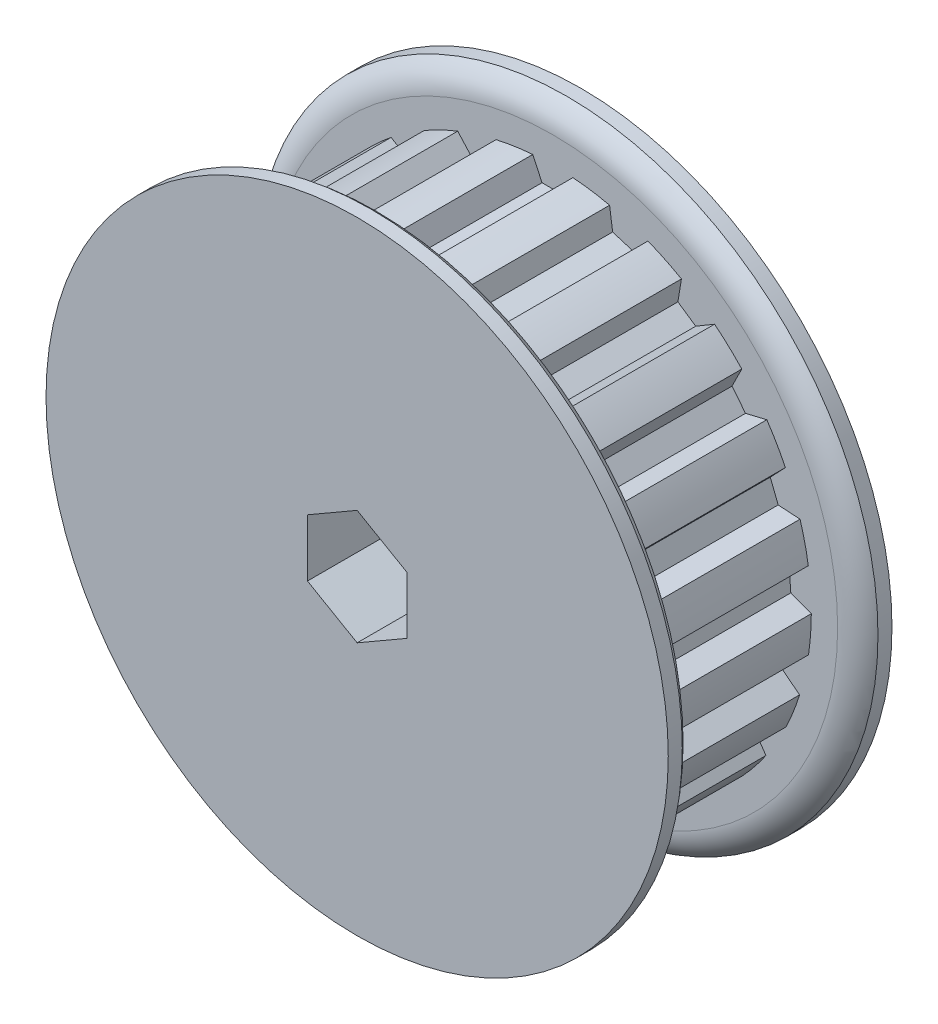
from build123d import *

# Parameters (mm, degrees)
CUT_EXTRUDE1_START = 1.397
CUT_EXTRUDE1_DEPTH = 10.7188
CIRPATTERN1_COUNT  = 21
SKETCH4_R          = 1.5875
CUT_EXTRUDE2_DEPTH = 31.241836167
CUT_EXTRUDE3_DEPTH = 1.190625
CIRPATTERN2_COUNT  = 2
CIRPATTERN2_ANGLE  = 90
CUT_EXTRUDE4_DEPTH = 50.8
SKETCH8_R          = 12.7
CUT_EXTRUDE5_DEPTH = 50.8


with BuildPart() as part:
    # Sketch2 → Revolve1 (revolve)
    with BuildSketch(Plane(origin=(0, 0, 0), x_dir=(0, 0, -1), z_dir=(1, 0, 0)), mode=Mode.PRIVATE) as revolve1_sk:
        with BuildLine():
            Line((-11.1125, 3.175), (11.1125, 3.175))
            Line((11.1125, 3.175), (11.1125, 19.8882))
            Line((11.1125, 19.8882), (10.21715, 19.8882))
            ThreePointArc((10.21715, 19.8882), (9.559562343, 19.158250378), (9.3218, 18.204983865))
            Line((9.3218, 18.204983865), (9.3218, 16.521767729))
            Line((9.3218, 16.521767729), (-1.397, 16.521767729))
            Line((-1.397, 16.521767729), (-1.397, 18.204983865))
            ThreePointArc((-1.397, 18.204983865), (-1.634762343, 19.158250378), (-2.29235, 19.8882))
            Line((-2.29235, 19.8882), (-3.1877, 19.8882))
            Line((-3.1877, 19.8882), (-3.1877, 11.9126))
            Line((-3.1877, 11.9126), (-11.1125, 11.9126))
            Line((-11.1125, 11.9126), (-11.1125, 3.175))
        make_face()
    revolve(revolve1_sk.sketch.rotate(Axis((0, 0, 11.1125), (0, 0, -1)), 90), axis=Axis((0, 0, 11.1125), (0, 0, -1)))

    # Sketch3 → Cut-Extrude1 (cut)
    with BuildSketch(Plane.XY.offset(CUT_EXTRUDE1_START)):
        with BuildLine():
            Line((-0.690489274, 15.2019), (0.690489274, 15.2019))
            Line((0.690489274, 15.2019), (1.2827, 16.4719))
            ThreePointArc((1.2827, 16.4719), (0, 16.521767729), (-1.2827, 16.4719))
            Line((-1.2827, 16.4719), (-0.690489274, 15.2019))
        make_face()
    cut_extrude1 = extrude(amount=-CUT_EXTRUDE1_DEPTH, mode=Mode.SUBTRACT)

    # CirPattern1: Cut-Extrude1 ×21 about axis
    cirpattern1_axis = Axis((0, 0, 0), (0, 0, 1))
    for i in range(1, CIRPATTERN1_COUNT):
        add(cut_extrude1.rotate(cirpattern1_axis, i * 360 / CIRPATTERN1_COUNT), mode=Mode.SUBTRACT)

    # Sketch4 → Cut-Extrude2 (cut, through all)
    with BuildSketch(Plane(origin=(0, 0, 0), x_dir=(1, 0, 0), z_dir=(0, 1, 0))):
        with Locations(Location((0, -7.1501, 0), (0, 0, 90))):
            Circle(SKETCH4_R)
    cut_extrude2 = extrude(amount=CUT_EXTRUDE2_DEPTH, mode=Mode.SUBTRACT)

    # Sketch5 → Revolve2 (revolve)
    with BuildSketch(Plane.XY.offset(7.1501), mode=Mode.PRIVATE) as revolve2_sk:
        Polygon((1.0795, 11.806349246), (1.5875, 11.298349246), (1.5875, 3.81), (0.9525, 3.175), (0, 3.175), (0, 11.806349246), align=None)
    revolve2 = revolve(revolve2_sk.sketch.rotate(Axis((0, 0, 7.1501), (0, 1, 0)), 90), axis=Axis((0, 0, 7.1501), (0, 1, 0)))

    # Sketch6 → Cut-Extrude3 (cut)
    with BuildSketch(Plane(origin=(0, 11.806349246, 0), x_dir=(1, 0, 0), z_dir=(0, 1, 0))):
        Polygon((0, -6.233556448), (-0.79375, -6.691828224), (-0.79375, -7.608371776), (0, -8.066643552), (0.79375, -7.608371776), (0.79375, -6.691828224), align=None)
    cut_extrude3 = extrude(amount=-CUT_EXTRUDE3_DEPTH, mode=Mode.SUBTRACT)

    # CirPattern2: Cut-Extrude2, Revolve2, Cut-Extrude3 ×2 about axis
    cirpattern2_axis = Axis((0, 0, 0), (0, 0, -1))
    add([cut_extrude2.rotate(cirpattern2_axis, i * CIRPATTERN2_ANGLE / (CIRPATTERN2_COUNT - 1)) for i in range(1, CIRPATTERN2_COUNT)], mode=Mode.SUBTRACT)
    add([revolve2.rotate(cirpattern2_axis, i * CIRPATTERN2_ANGLE / (CIRPATTERN2_COUNT - 1)) for i in range(1, CIRPATTERN2_COUNT)])
    add([cut_extrude3.rotate(cirpattern2_axis, i * CIRPATTERN2_ANGLE / (CIRPATTERN2_COUNT - 1)) for i in range(1, CIRPATTERN2_COUNT)], mode=Mode.SUBTRACT)

    # Sketch7 → Cut-Extrude4 (cut)
    with BuildSketch(Plane.XY.offset(11.1125)):
        Polygon((0, 3.666174209), (-3.175, 1.833087105), (-3.175, -1.833087105), (0, -3.666174209), (3.175, -1.833087105), (3.175, 1.833087105), align=None)
    extrude(amount=-CUT_EXTRUDE4_DEPTH, mode=Mode.SUBTRACT)

    # Sketch8 → Cut-Extrude5 (cut)
    with BuildSketch(Plane.XY.offset(3.1877)):
        Circle(SKETCH8_R)
    extrude(amount=CUT_EXTRUDE5_DEPTH, mode=Mode.SUBTRACT)


solid = part.part
